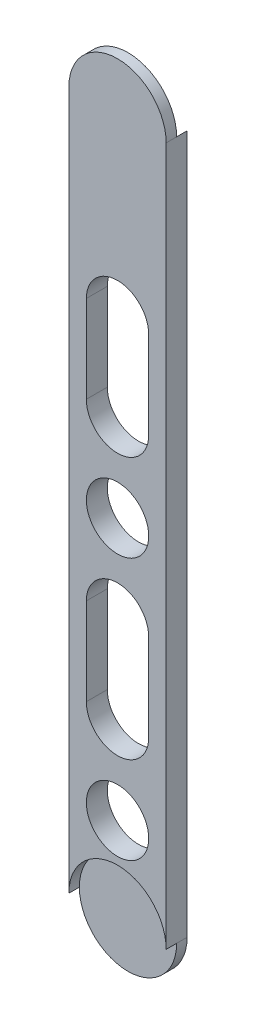
from build123d import *

# Parameters (mm, degrees)
ESQUISSE1_W             = 27.85
ESQUISSE1_H             = 200
BOSS_EXTRU_1_DEPTH      = 6
ESQUISSE2_R             = 13.925
ENL_V_MAT_EXTRU_1_DEPTH = 3
ESQUISSE3_R             = 13.925
ENL_V_MAT_EXTRU_2_DEPTH = 3
ESQUISSE5_W             = 17.85
ESQUISSE5_H             = 25
ESQUISSE5_R             = 8.925
ENL_V_MAT_EXTRU_3_DEPTH = 10


with BuildPart() as part:
    # Esquisse1 → Boss.-Extru.1 (new body)
    with BuildSketch(Plane.XY):
        with Locations((41.042105263, 90.919078947)):
            Rectangle(ESQUISSE1_W, ESQUISSE1_H)
        with BuildLine():
            Line((27.117105263, -9.080921053), (54.967105263, -9.080921053))
            ThreePointArc((54.967105263, -9.080921053), (41.042105263, -23.005921053), (27.117105263, -9.080921053))
        make_face()
        with BuildLine():
            ThreePointArc((27.117105263, 190.919078947), (41.042105263, 204.844078947), (54.967105263, 190.919078947))
            Line((54.967105263, 190.919078947), (27.117105263, 190.919078947))
        make_face()
    extrude(amount=BOSS_EXTRU_1_DEPTH)

    # Esquisse2 → Enlèv. mat.-Extru.1 (cut)
    with BuildSketch(Plane.XY.offset(6)):
        with Locations((41.042105263, -9.080921053)):
            Circle(ESQUISSE2_R)
    extrude(amount=-ENL_V_MAT_EXTRU_1_DEPTH, mode=Mode.SUBTRACT)

    # Esquisse3 → Enlèv. mat.-Extru.2 (cut)
    with BuildSketch(Plane(origin=(0, 0, 0), x_dir=(-1, 0, 0), z_dir=(0, 0, -1))):
        with Locations((-41.042105263, 190.919078947)):
            Circle(ESQUISSE3_R)
    extrude(amount=-ENL_V_MAT_EXTRU_2_DEPTH, mode=Mode.SUBTRACT)

    # Esquisse5 → Enlèv. mat.-Extru.3 (cut)
    with BuildSketch(Plane.XY.offset(6)):
        with BuildLine():
            ThreePointArc((32.117105263, 140.919078947), (41.042105263, 149.844078947), (49.967105263, 140.919078947))
            Line((49.967105263, 140.919078947), (32.117105263, 140.919078947))
        make_face()
        with Locations((41.042105263, 128.419078947)):
            Rectangle(ESQUISSE5_W, ESQUISSE5_H)
        with BuildLine():
            ThreePointArc((49.967105263, 115.919078947), (41.042105263, 106.994078947), (32.117105263, 115.919078947))
            Line((32.117105263, 115.919078947), (49.967105263, 115.919078947))
        make_face()
        with Locations((41.042105263, 90.919078947)):
            Circle(ESQUISSE5_R)
        with BuildLine():
            ThreePointArc((32.117105263, 65.919078947), (41.042105263, 74.844078947), (49.967105263, 65.919078947))
            Line((49.967105263, 65.919078947), (32.117105263, 65.919078947))
        make_face()
        with Locations((41.042105263, 53.419078947)):
            Rectangle(ESQUISSE5_W, ESQUISSE5_H)
        with BuildLine():
            Line((32.117105263, 40.919078947), (49.967105263, 40.919078947))
            ThreePointArc((49.967105263, 40.919078947), (41.042105263, 31.994078947), (32.117105263, 40.919078947))
        make_face()
        with Locations((41.042105263, 15.919078947)):
            Circle(ESQUISSE5_R)
    extrude(amount=-ENL_V_MAT_EXTRU_3_DEPTH, mode=Mode.SUBTRACT)


solid = part.part
